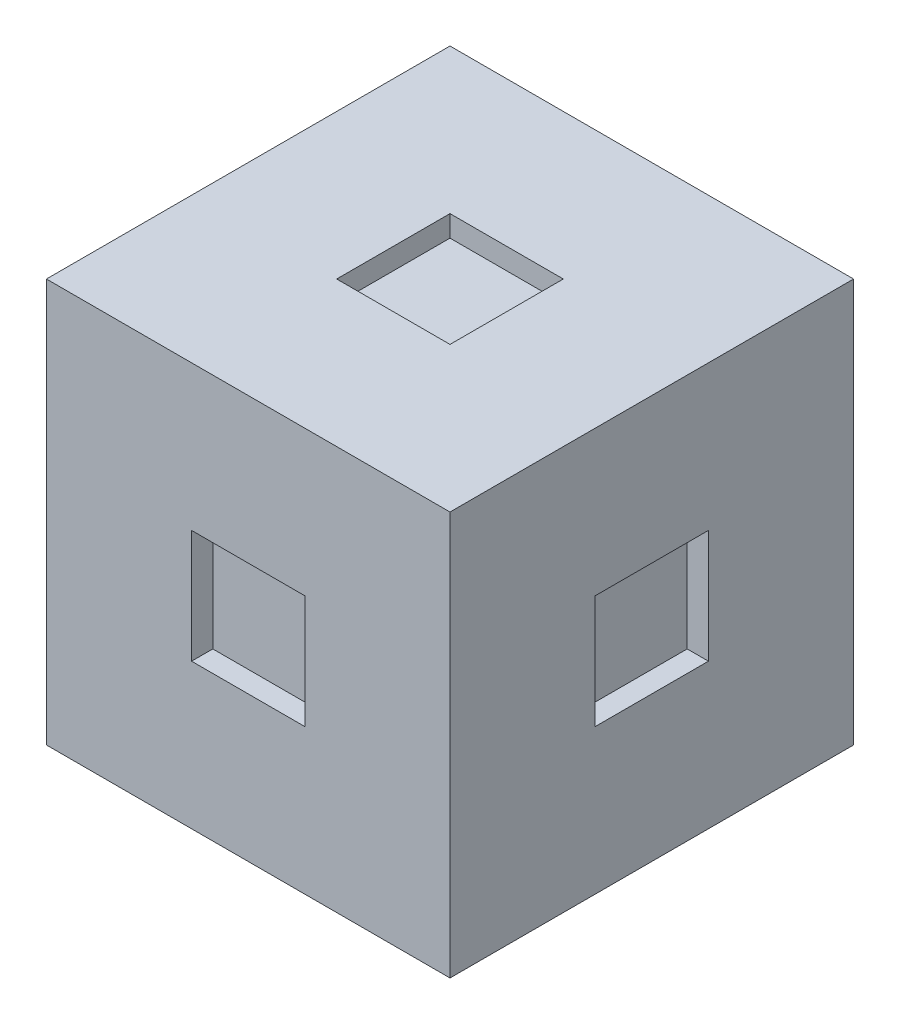
from build123d import *

# Parameters (mm, degrees)
SKETCH_1_W          = 57
SKETCH_1_H          = 57
EXTRUDE_1_DEPTH     = 57
SKETCH_2_W          = 16
SKETCH_2_H          = 16
CUT_EXTRUDE_1_DEPTH = 3
SKETCH_3_W          = 16
SKETCH_3_H          = 16
CUT_EXTRUDE_2_DEPTH = 3
SKETCH_4_W          = 16
SKETCH_4_H          = 16
CUT_EXTRUDE_3_DEPTH = 3
SKETCH_5_W          = 16
SKETCH_5_H          = 16
CUT_EXTRUDE_4_DEPTH = 3
SKETCH_6_W          = 16
SKETCH_6_H          = 16
CUT_EXTRUDE_5_DEPTH = 3
SKETCH_7_W          = 16
SKETCH_7_H          = 16
CUT_EXTRUDE_6_DEPTH = 3


with BuildPart() as part:
    # 草图1 → 凸台-拉伸1 (new body)
    with BuildSketch(Plane(origin=(0, 0, 0), x_dir=(1, 0, 0), z_dir=(0, 1, 0))):
        Rectangle(SKETCH_1_W, SKETCH_1_H)
    extrude(amount=EXTRUDE_1_DEPTH)

    # 草图2 → 切除-拉伸1 (cut)
    with BuildSketch(Plane.XY.offset(28.5)):
        with Locations((0, 28.5)):
            Rectangle(SKETCH_2_W, SKETCH_2_H)
    extrude(amount=-CUT_EXTRUDE_1_DEPTH, mode=Mode.SUBTRACT)

    # 草图3 → 切除-拉伸2 (cut)
    with BuildSketch(Plane(origin=(28.5, 0, 0), x_dir=(0, 0, -1), z_dir=(1, 0, 0))):
        with Locations((0, 28.5)):
            Rectangle(SKETCH_3_W, SKETCH_3_H)
    extrude(amount=-CUT_EXTRUDE_2_DEPTH, mode=Mode.SUBTRACT)

    # 草图4 → 切除-拉伸3 (cut)
    with BuildSketch(Plane(origin=(0, 0, -28.5), x_dir=(-1, 0, 0), z_dir=(0, 0, -1))):
        with Locations((0, 28.5)):
            Rectangle(SKETCH_4_W, SKETCH_4_H)
    extrude(amount=-CUT_EXTRUDE_3_DEPTH, mode=Mode.SUBTRACT)

    # 草图5 → 切除-拉伸4 (cut)
    with BuildSketch(Plane.ZY.offset(28.5)):
        with Locations((0, 28.5)):
            Rectangle(SKETCH_5_W, SKETCH_5_H)
    extrude(amount=-CUT_EXTRUDE_4_DEPTH, mode=Mode.SUBTRACT)

    # 草图6 → 切除-拉伸5 (cut)
    with BuildSketch(Plane(origin=(0, 57, 0), x_dir=(1, 0, 0), z_dir=(0, 1, 0))):
        Rectangle(SKETCH_6_W, SKETCH_6_H)
    extrude(amount=-CUT_EXTRUDE_5_DEPTH, mode=Mode.SUBTRACT)

    # 草图7 → 切除-拉伸6 (cut)
    with BuildSketch(Plane.XZ):
        Rectangle(SKETCH_7_W, SKETCH_7_H)
    extrude(amount=-CUT_EXTRUDE_6_DEPTH, mode=Mode.SUBTRACT)


solid = part.part
